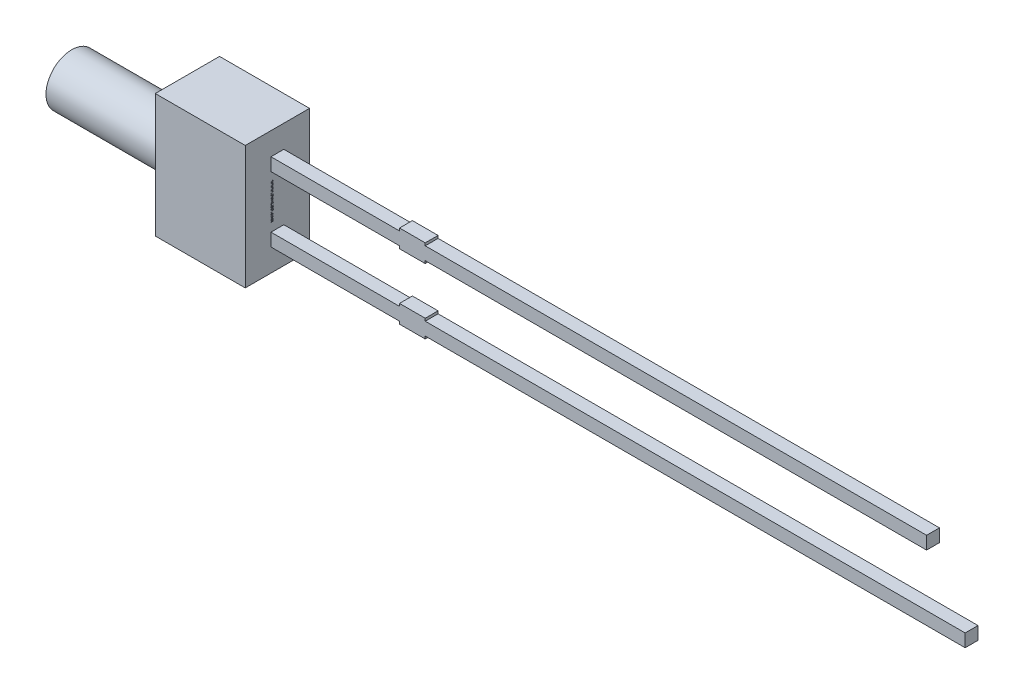
from build123d import *

# Parameters (mm, degrees)
SKETCH1_W          = 3.5
SKETCH1_H          = 4.8
EXTRUDE1_DEPTH     = 1.25
SKETCH1_4_W        = 5
SKETCH1_4_H        = 0.5
SKETCH1_4_W_2      = 1
SKETCH1_4_W_3      = 19.5
SKETCH1_4_H_2      = 0.1
SKETCH1_4_W_4      = 21
EXTRUDE2_DEPTH     = 0.25
SKETCH3_R          = 1
EXTRUDE3_DEPTH     = 4.5
SKETCH4_W          = 0.026582278
SKETCH4_H          = 0.025316456
CUT_EXTRUDE1_DEPTH = 0.01


with BuildPart() as part:
    # Sketch1 → Extrude1 (new body, symmetric)
    with BuildSketch(Plane.XY):
        Rectangle(SKETCH1_W, SKETCH1_H)
    extrude(amount=EXTRUDE1_DEPTH, both=True)

    # Sketch1_4 → Extrude2 (add, symmetric)
    with BuildSketch(Plane.XY):
        with Locations((4.25, 1.27)):
            Rectangle(SKETCH1_4_W, SKETCH1_4_H)
        with Locations((7.25, 1.27)):
            Rectangle(SKETCH1_4_W_2, SKETCH1_4_H)
        with Locations((17.5, 1.27)):
            Rectangle(SKETCH1_4_W_3, SKETCH1_4_H)
        with Locations((7.25, 1.57)):
            Rectangle(SKETCH1_4_W_2, SKETCH1_4_H_2)
        with Locations((7.25, 0.97)):
            Rectangle(SKETCH1_4_W_2, SKETCH1_4_H_2)
        with Locations((7.25, -1.27)):
            Rectangle(SKETCH1_4_W_2, SKETCH1_4_H)
        with Locations((7.25, -0.97)):
            Rectangle(SKETCH1_4_W_2, SKETCH1_4_H_2)
        with Locations((18.25, -1.27)):
            Rectangle(SKETCH1_4_W_4, SKETCH1_4_H)
        with Locations((4.25, -1.27)):
            Rectangle(SKETCH1_4_W, SKETCH1_4_H)
        with Locations((7.25, -1.57)):
            Rectangle(SKETCH1_4_W_2, SKETCH1_4_H_2)
    extrude(amount=EXTRUDE2_DEPTH, both=True)

    # Sketch3 → Extrude3 (add)
    with BuildSketch(Plane.ZY.offset(1.75)):
        with Locations(Location((0, 0, 0), (0, 0, 180))):  # turned: the seam where the file's is
            Circle(SKETCH3_R)
    extrude(amount=EXTRUDE3_DEPTH)

    # Sketch4 → Cut-Extrude1 (cut)
    with BuildSketch(Plane(origin=(1.75, 0, 0), x_dir=(0, 0, -1), z_dir=(1, 0, 0))):
        Polygon((-0.175316456, 0.572151899), (-0.25, 0.595609177), (-0.25, 0.620352057), (-0.199663766, 0.636768196), (-0.25, 0.652294304), (-0.25, 0.678026108), (-0.175316456, 0.701265823), (-0.175316456, 0.676087816), (-0.226799842, 0.663093354), (-0.175316456, 0.646677215), (-0.175316456, 0.625178006), (-0.226799842, 0.608860759), (-0.175316456, 0.596044304), align=None)
        Polygon((-0.175316456, 0.437974684), (-0.25, 0.461431962), (-0.25, 0.486174842), (-0.199663766, 0.502590981), (-0.25, 0.518117089), (-0.25, 0.543848892), (-0.175316456, 0.567088608), (-0.175316456, 0.541910601), (-0.226799842, 0.528916139), (-0.175316456, 0.5125), (-0.175316456, 0.491000791), (-0.226799842, 0.474683544), (-0.175316456, 0.461867089), align=None)
        Polygon((-0.175316456, 0.303797468), (-0.25, 0.327254747), (-0.25, 0.351997627), (-0.199663766, 0.368413766), (-0.25, 0.383939873), (-0.25, 0.409671677), (-0.175316456, 0.432911392), (-0.175316456, 0.407733386), (-0.226799842, 0.394738924), (-0.175316456, 0.378322785), (-0.175316456, 0.356823576), (-0.226799842, 0.340506329), (-0.175316456, 0.327689873), align=None)
        with Locations((-0.236708861, 0.275949367)):
            Rectangle(SKETCH4_W, SKETCH4_H)
        with BuildLine():
            add(Edge.make_bspline(
                [(-0.218829114, 0.159493671), (-0.220051248, 0.159530169), (-0.22245111, 0.15960184), (-0.225958798, 0.160211426), (-0.229283102, 0.161205393), (-0.232447248, 0.162577732), (-0.235416736, 0.164371189), (-0.238219628, 0.16655446), (-0.240824172, 0.169143343), (-0.243260547, 0.172090146), (-0.245442658, 0.175387089), (-0.247348691, 0.178984804), (-0.248943362, 0.18286483), (-0.250282428, 0.187013042), (-0.251270861, 0.191459588), (-0.251994849, 0.196177087), (-0.252468166, 0.201170514), (-0.252510134, 0.204594091), (-0.252531646, 0.206348892)],
                knots=[0, 0, 0, 0, 0.907312236, 1.78165839, 2.635367075, 3.479697475, 4.336364812, 5.205276731, 6.11257575, 7.058770404, 8.040786331, 9.044147278, 10.078219212, 11.153049307, 12.278104542, 13.457648573, 14.696882856, 16, 16, 16, 16], degree=3))
            add(Edge.make_bspline(
                [(-0.252531646, 0.206348892), (-0.252507574, 0.208367148), (-0.252460949, 0.21227633), (-0.25203235, 0.217939855), (-0.251386211, 0.223207892), (-0.250419669, 0.228103607), (-0.249218904, 0.232708206), (-0.247927612, 0.237141474), (-0.246463197, 0.241422786), (-0.245363039, 0.244195876), (-0.244818038, 0.24556962)],
                knots=[0, 0, 0, 0, 1.203215828, 2.33052265, 3.384689099, 4.366106119, 5.303329643, 6.221311756, 7.118865988, 8, 8, 8, 8], degree=3))
            Line((-0.244818038, 0.24556962), (-0.220886076, 0.24556962))
            Line((-0.220886076, 0.24556962), (-0.220886076, 0.242721519))
            add(Edge.make_bspline(
                [(-0.220886076, 0.242721519), (-0.221967531, 0.241356205), (-0.224124092, 0.238633592), (-0.226886697, 0.234200359), (-0.22928886, 0.229552713), (-0.231262862, 0.224707243), (-0.232849186, 0.219810398), (-0.233942713, 0.21493502), (-0.234690062, 0.210169433), (-0.234770569, 0.207010864), (-0.234810127, 0.205458861)],
                knots=[0, 0, 0, 0, 1.030622468, 2.055194264, 3.087043286, 4.125157485, 5.149848264, 6.130935704, 7.081611712, 8, 8, 8, 8], degree=3))
            add(Edge.make_bspline(
                [(-0.234810127, 0.205458861), (-0.234809232, 0.205030082), (-0.234807317, 0.2041121), (-0.234678474, 0.202644063), (-0.234585311, 0.200985464), (-0.234376093, 0.199206598), (-0.23415751, 0.197415781), (-0.23377719, 0.195761121), (-0.233415351, 0.194257482), (-0.233047173, 0.193351), (-0.232871835, 0.192919304)],
                knots=[0, 0, 0, 0, 0.806378557, 1.726393851, 2.771014456, 3.931269413, 5.096090628, 6.161710732, 7.124547685, 8, 8, 8, 8], degree=3))
            add(Edge.make_bspline(
                [(-0.232871835, 0.192919304), (-0.232644012, 0.192439517), (-0.23219629, 0.191496634), (-0.231378683, 0.190201714), (-0.230507381, 0.189019042), (-0.229541962, 0.187957582), (-0.228364053, 0.187107314), (-0.226963197, 0.186479113), (-0.225312897, 0.186136019), (-0.224137886, 0.186096725), (-0.223516614, 0.186075949)],
                knots=[0, 0, 0, 0, 1.024407818, 2.013179384, 2.949802342, 3.859052226, 4.77034807, 5.732977883, 6.801339628, 8, 8, 8, 8], degree=3))
            add(Edge.make_bspline(
                [(-0.223516614, 0.186075949), (-0.222970718, 0.186107391), (-0.221897325, 0.186169215), (-0.220369329, 0.186751006), (-0.218947452, 0.187633905), (-0.217686737, 0.188920927), (-0.216529299, 0.190515003), (-0.215559002, 0.19247074), (-0.214678928, 0.194723719), (-0.214261659, 0.196368178), (-0.214042722, 0.197231013)],
                knots=[0, 0, 0, 0, 0.825212765, 1.622611382, 2.449701629, 3.348069183, 4.336544339, 5.428209675, 6.6506027, 8, 8, 8, 8], degree=3))
            add(Edge.make_bspline(
                [(-0.214042722, 0.197231013), (-0.213594981, 0.19919974), (-0.212677791, 0.203232648), (-0.211530684, 0.209380757), (-0.210264611, 0.215510984), (-0.20905507, 0.219469696), (-0.20846519, 0.221400316)],
                knots=[0, 0, 0, 0, 0.976104583, 1.999535498, 3.024395274, 4, 4, 4, 4], degree=3))
            add(Edge.make_bspline(
                [(-0.20846519, 0.221400316), (-0.208112197, 0.222438832), (-0.207425064, 0.224460401), (-0.206263439, 0.227351945), (-0.204993487, 0.230013057), (-0.203638356, 0.232453168), (-0.202164358, 0.23465249), (-0.200630968, 0.236647679), (-0.198977131, 0.238391205), (-0.197245211, 0.239938889), (-0.195393209, 0.241262203), (-0.193449072, 0.242416954), (-0.191388607, 0.243392589), (-0.189227318, 0.244201473), (-0.18694845, 0.244818545), (-0.184571576, 0.245239801), (-0.182088216, 0.24553819), (-0.180393863, 0.245559001), (-0.179529272, 0.24556962)],
                knots=[0, 0, 0, 0, 1.287286806, 2.505824366, 3.654938963, 4.74627059, 5.778586806, 6.75996495, 7.696030012, 8.595059759, 9.482019644, 10.363222407, 11.245851011, 12.154256429, 13.068444161, 14.012503255, 14.985824751, 16, 16, 16, 16], degree=3))
            add(Edge.make_bspline(
                [(-0.179529272, 0.24556962), (-0.178373127, 0.245532318), (-0.176097855, 0.245458909), (-0.172768811, 0.24485748), (-0.169620074, 0.24383089), (-0.166616611, 0.242444827), (-0.163803525, 0.240616199), (-0.161124978, 0.238431404), (-0.158653386, 0.235807357), (-0.156353053, 0.232830235), (-0.154273654, 0.229542851), (-0.152443098, 0.226003867), (-0.150906446, 0.222234578), (-0.149632552, 0.218249032), (-0.148677881, 0.214030563), (-0.14795895, 0.20959333), (-0.147545768, 0.204919541), (-0.147494518, 0.20172812), (-0.147468354, 0.200098892)],
                knots=[0, 0, 0, 0, 0.894990994, 1.761326291, 2.609044902, 3.454222546, 4.315366365, 5.200560057, 6.125081389, 7.100429509, 8.110379559, 9.133447974, 10.182136699, 11.259192205, 12.370181258, 13.528580438, 14.738335141, 16, 16, 16, 16], degree=3))
            add(Edge.make_bspline(
                [(-0.147468354, 0.200098892), (-0.147490546, 0.198430205), (-0.147534891, 0.19509566), (-0.147912869, 0.190114218), (-0.148468097, 0.185153716), (-0.149309803, 0.180289886), (-0.15028622, 0.175599331), (-0.151382015, 0.171186095), (-0.15261998, 0.167106634), (-0.153574325, 0.16453297), (-0.15403481, 0.163291139)],
                knots=[0, 0, 0, 0, 1.065403572, 2.129000689, 3.188532477, 4.251604565, 5.279552602, 6.247508681, 7.154397237, 8, 8, 8, 8], degree=3))
            Line((-0.15403481, 0.163291139), (-0.176582278, 0.163291139))
            Line((-0.176582278, 0.163291139), (-0.176582278, 0.166119462))
            add(Edge.make_bspline(
                [(-0.176582278, 0.166119462), (-0.175781932, 0.167192367), (-0.174145202, 0.169386485), (-0.17206153, 0.173046122), (-0.170103664, 0.177004358), (-0.168419505, 0.181283188), (-0.166960024, 0.185742216), (-0.165940858, 0.190325174), (-0.165299048, 0.194951338), (-0.165226273, 0.198053049), (-0.165189873, 0.19960443)],
                knots=[0, 0, 0, 0, 0.892283326, 1.824742884, 2.804416662, 3.836872171, 4.8899239, 5.931447339, 6.965372909, 8, 8, 8, 8], degree=3))
            add(Edge.make_bspline(
                [(-0.165189873, 0.19960443), (-0.165211326, 0.200700098), (-0.165254228, 0.202891315), (-0.165644912, 0.206159523), (-0.166275806, 0.209401584), (-0.167095088, 0.211442107), (-0.167503956, 0.212460443)],
                knots=[0, 0, 0, 0, 0.999146175, 1.998183711, 3.000980573, 4, 4, 4, 4], degree=3))
            add(Edge.make_bspline(
                [(-0.167503956, 0.212460443), (-0.167705423, 0.212893946), (-0.168108222, 0.213760664), (-0.168880786, 0.214967308), (-0.169809597, 0.216071977), (-0.170861589, 0.217064055), (-0.172017962, 0.217932452), (-0.173292788, 0.218547803), (-0.174655703, 0.218923676), (-0.175590934, 0.218965835), (-0.176068038, 0.218987342)],
                knots=[0, 0, 0, 0, 1.00524851, 2.009826503, 3.004679593, 4.035271301, 5.048246368, 6.034938417, 6.997532266, 8, 8, 8, 8], degree=3))
            add(Edge.make_bspline(
                [(-0.176068038, 0.218987342), (-0.176706203, 0.218952904), (-0.177925679, 0.218887095), (-0.179641475, 0.218280511), (-0.181119909, 0.217295678), (-0.182114829, 0.216135073), (-0.182812267, 0.215017943), (-0.183322777, 0.213982284), (-0.183806136, 0.212773057), (-0.184303605, 0.211401809), (-0.184794792, 0.209865482), (-0.185270339, 0.208156925), (-0.185719635, 0.206274208), (-0.186005825, 0.204958333), (-0.186155063, 0.204272152)],
                knots=[0, 0, 0, 0, 1.173816843, 2.243057204, 3.312297565, 4.415174738, 5.03266065, 5.73970059, 6.541434878, 7.433956553, 8.430083051, 9.515931566, 10.70464786, 12, 12, 12, 12], degree=3))
            add(Edge.make_bspline(
                [(-0.186155063, 0.204272152), (-0.186531125, 0.202439363), (-0.187270003, 0.198838337), (-0.188373491, 0.193437153), (-0.18964846, 0.18793438), (-0.190797263, 0.184269053), (-0.191396361, 0.182357595)],
                knots=[0, 0, 0, 0, 0.995744513, 1.956417928, 2.934277412, 4, 4, 4, 4], degree=3))
            add(Edge.make_bspline(
                [(-0.191396361, 0.182357595), (-0.191715605, 0.181411041), (-0.192340097, 0.179559428), (-0.19342638, 0.176918797), (-0.194600363, 0.174471738), (-0.195841894, 0.172204706), (-0.19718586, 0.170130736), (-0.198608507, 0.168236053), (-0.200135416, 0.166552235), (-0.201748644, 0.16505467), (-0.203458744, 0.16373551), (-0.205297817, 0.162603212), (-0.207246619, 0.161630984), (-0.209332819, 0.160861379), (-0.211527406, 0.160243358), (-0.213858774, 0.159820261), (-0.21630315, 0.159526278), (-0.217977728, 0.159504661), (-0.218829114, 0.159493671)],
                knots=[0, 0, 0, 0, 1.237467875, 2.420686895, 3.535046182, 4.599015201, 5.620884487, 6.594603852, 7.531477383, 8.433220087, 9.318759595, 10.202828513, 11.105163009, 12.01247538, 12.953896178, 13.926381251, 14.945733412, 16, 16, 16, 16], degree=3))
        make_face()
        with BuildLine():
            Line((-0.25, 0.067088608), (-0.25, 0.091139241))
            Line((-0.25, 0.091139241), (-0.242167722, 0.091139241))
            add(Edge.make_bspline(
                [(-0.242167722, 0.091139241), (-0.24297628, 0.092232549), (-0.244535168, 0.094340433), (-0.246615386, 0.097513458), (-0.248390652, 0.100539548), (-0.249949873, 0.103453039), (-0.251125258, 0.106475242), (-0.251953324, 0.109706756), (-0.252453097, 0.113209581), (-0.252504881, 0.115636475), (-0.252531646, 0.116890823)],
                knots=[0, 0, 0, 0, 1.150872466, 2.218865267, 3.209461834, 4.120482262, 5.012764827, 5.946708227, 6.938749913, 8, 8, 8, 8], degree=3))
            add(Edge.make_bspline(
                [(-0.252531646, 0.116890823), (-0.252508927, 0.117907175), (-0.252464686, 0.119886305), (-0.252119808, 0.122763545), (-0.251582157, 0.125471173), (-0.250774566, 0.127986213), (-0.249808763, 0.130350202), (-0.248528805, 0.132487752), (-0.247098631, 0.134491354), (-0.245391585, 0.136273026), (-0.243493852, 0.137888648), (-0.241361392, 0.139271198), (-0.239028466, 0.140448909), (-0.236476612, 0.141390006), (-0.233718309, 0.142145096), (-0.230739061, 0.142669028), (-0.227551934, 0.142989621), (-0.225356803, 0.14302156), (-0.224228639, 0.143037975)],
                knots=[0, 0, 0, 0, 1.109008058, 2.159558935, 3.158726032, 4.116861086, 5.039058877, 5.938775559, 6.82970133, 7.720510853, 8.624361809, 9.544451588, 10.487360536, 11.471068125, 12.508000841, 13.604731202, 14.768976642, 16, 16, 16, 16], degree=3))
            Line((-0.224228639, 0.143037975), (-0.175316456, 0.143037975))
            Line((-0.175316456, 0.143037975), (-0.175316456, 0.118987342))
            Line((-0.175316456, 0.118987342), (-0.21289557, 0.118987342))
            add(Edge.make_bspline(
                [(-0.21289557, 0.118987342), (-0.213812041, 0.118985706), (-0.215566256, 0.118982576), (-0.218072063, 0.118900237), (-0.220340235, 0.118779336), (-0.222382264, 0.118640631), (-0.224229015, 0.118387615), (-0.225895176, 0.118009906), (-0.227414778, 0.11753908), (-0.228321479, 0.117074761), (-0.228757911, 0.116851266)],
                knots=[0, 0, 0, 0, 1.361401701, 2.605856924, 3.723918663, 4.735739235, 5.645738665, 6.489217889, 7.27279937, 8, 8, 8, 8], degree=3))
            add(Edge.make_bspline(
                [(-0.228757911, 0.116851266), (-0.229156626, 0.116621259), (-0.229940466, 0.116169086), (-0.230946644, 0.115248796), (-0.231790911, 0.114170053), (-0.23244694, 0.112892449), (-0.232945889, 0.111405901), (-0.233286125, 0.109677971), (-0.233501627, 0.107692609), (-0.233529535, 0.106283591), (-0.233544304, 0.105537975)],
                knots=[0, 0, 0, 0, 0.849138082, 1.669332372, 2.503455908, 3.370611167, 4.311442699, 5.394692208, 6.621337967, 8, 8, 8, 8], degree=3))
            add(Edge.make_bspline(
                [(-0.233544304, 0.105537975), (-0.233526947, 0.104996691), (-0.233491259, 0.103883773), (-0.233258814, 0.102172461), (-0.232902139, 0.100375884), (-0.232242283, 0.097861301), (-0.231056104, 0.094694674), (-0.229701697, 0.092335372), (-0.229015032, 0.091139241)],
                knots=[0, 0, 0, 0, 0.638127216, 1.312033637, 2.033062677, 2.79661882, 4.375931797, 6, 6, 6, 6], degree=3))
            Line((-0.229015032, 0.091139241), (-0.175316456, 0.091139241))
            Line((-0.175316456, 0.091139241), (-0.175316456, 0.067088608))
            Line((-0.175316456, 0.067088608), (-0.25, 0.067088608))
        make_face()
        with BuildLine():
            Line((-0.25, -0.030379747), (-0.25, -0.006329114))
            Line((-0.25, -0.006329114), (-0.212420886, -0.006329114))
            add(Edge.make_bspline(
                [(-0.212420886, -0.006329114), (-0.210890843, -0.0063046), (-0.207839818, -0.006255716), (-0.204077407, -0.005973592), (-0.201235083, -0.00559507), (-0.199397202, -0.005225415), (-0.197849063, -0.004793715), (-0.196963303, -0.004381435), (-0.196558544, -0.004193038)],
                knots=[0, 0, 0, 0, 1.709124929, 3.408128882, 4.211124727, 4.91016634, 5.501986363, 6, 6, 6, 6], degree=3))
            add(Edge.make_bspline(
                [(-0.196558544, -0.004193038), (-0.196160491, -0.003948575), (-0.195380051, -0.003469272), (-0.194367038, -0.002531948), (-0.193538197, -0.001438061), (-0.192856647, -0.000167292), (-0.192386066, 0.001323905), (-0.191992836, 0.003040645), (-0.191825927, 0.005027263), (-0.191790767, 0.006434533), (-0.191772152, 0.007179589)],
                knots=[0, 0, 0, 0, 0.86006424, 1.686277094, 2.52783008, 3.38194165, 4.331801563, 5.402842185, 6.624978739, 8, 8, 8, 8], degree=3))
            add(Edge.make_bspline(
                [(-0.191772152, 0.007179589), (-0.191828889, 0.00831141), (-0.191944743, 0.010622505), (-0.19265625, 0.013484698), (-0.193475209, 0.015815302), (-0.19423404, 0.017667827), (-0.195205482, 0.019576457), (-0.195927304, 0.020855869), (-0.196301424, 0.021518987)],
                knots=[0, 0, 0, 0, 1.338371478, 2.732853438, 3.468019217, 4.261884641, 5.099136535, 6, 6, 6, 6], degree=3))
            Line((-0.196301424, 0.021518987), (-0.25, 0.021518987))
            Line((-0.25, 0.021518987), (-0.25, 0.04556962))
            Line((-0.25, 0.04556962), (-0.175316456, 0.04556962))
            Line((-0.175316456, 0.04556962), (-0.175316456, 0.021518987))
            Line((-0.175316456, 0.021518987), (-0.183148734, 0.021518987))
            add(Edge.make_bspline(
                [(-0.183148734, 0.021518987), (-0.182342583, 0.020461581), (-0.18077336, 0.018403276), (-0.17873294, 0.015224038), (-0.176934171, 0.01214014), (-0.175421354, 0.009087131), (-0.174214579, 0.005972176), (-0.17340359, 0.002709417), (-0.172859787, -0.000706989), (-0.172810094, -0.003043704), (-0.17278481, -0.004232595)],
                knots=[0, 0, 0, 0, 1.126119141, 2.192057864, 3.198061997, 4.149848529, 5.076251285, 6.021887753, 6.99356175, 8, 8, 8, 8], degree=3))
            add(Edge.make_bspline(
                [(-0.17278481, -0.004232595), (-0.172810199, -0.005228866), (-0.172859763, -0.007173765), (-0.173169473, -0.010008526), (-0.173720137, -0.012679947), (-0.174517966, -0.015172221), (-0.175503578, -0.017514841), (-0.176735093, -0.019676785), (-0.178193516, -0.021668856), (-0.179854519, -0.023497257), (-0.181744245, -0.025128075), (-0.18386151, -0.026545111), (-0.186204606, -0.027725092), (-0.188764915, -0.028695805), (-0.191530024, -0.029470228), (-0.19452599, -0.029985359), (-0.197730169, -0.030339143), (-0.199946212, -0.030365941), (-0.201087816, -0.030379747)],
                knots=[0, 0, 0, 0, 1.08848837, 2.124922927, 3.110950502, 4.063144162, 4.979605775, 5.882838355, 6.774625441, 7.671951181, 8.57587277, 9.494821853, 10.448322275, 11.435533005, 12.482327682, 13.580118324, 14.753386918, 16, 16, 16, 16], degree=3))
            Line((-0.201087816, -0.030379747), (-0.25, -0.030379747))
        make_face()
        Polygon((-0.25, -0.125316456), (-0.25, -0.053164557), (-0.15, -0.053164557), (-0.15, -0.078481013), (-0.231012658, -0.078481013), (-0.231012658, -0.125316456), align=None)
        Polygon((-0.25, -0.212658228), (-0.25, -0.140506329), (-0.15, -0.140506329), (-0.15, -0.212658228), (-0.168987342, -0.212658228), (-0.168987342, -0.165822785), (-0.186708861, -0.165822785), (-0.186708861, -0.208860759), (-0.205696203, -0.208860759), (-0.205696203, -0.165822785), (-0.231012658, -0.165822785), (-0.231012658, -0.212658228), align=None)
        with BuildLine():
            add(Edge.make_bspline(
                [(-0.200098892, -0.329113924), (-0.201246581, -0.329094609), (-0.203519467, -0.329056357), (-0.206884274, -0.328761165), (-0.210149949, -0.32823514), (-0.213334198, -0.327555959), (-0.216413126, -0.326633453), (-0.219420703, -0.325551739), (-0.222326196, -0.324242093), (-0.225127631, -0.322737241), (-0.227799734, -0.321087768), (-0.230319942, -0.319313019), (-0.23270316, -0.31746724), (-0.234898054, -0.315477927), (-0.236940074, -0.313398746), (-0.238830888, -0.311223217), (-0.240534319, -0.308918153), (-0.241557203, -0.30731099), (-0.242068829, -0.30650712)],
                knots=[0, 0, 0, 0, 1.105570398, 2.18947457, 3.250358341, 4.290584537, 5.323553275, 6.344225964, 7.367641686, 8.3905646, 9.405808457, 10.390761353, 11.358902336, 12.307789878, 13.241960776, 14.165076779, 15.082208636, 16, 16, 16, 16], degree=3))
            add(Edge.make_bspline(
                [(-0.242068829, -0.30650712), (-0.242780968, -0.305267892), (-0.244208881, -0.302783112), (-0.245877472, -0.298799278), (-0.247281588, -0.294673795), (-0.248336012, -0.290323409), (-0.249063056, -0.285676399), (-0.249623862, -0.28067499), (-0.249925622, -0.275267401), (-0.249974642, -0.271532506), (-0.25, -0.269600475)],
                knots=[0, 0, 0, 0, 0.896288622, 1.797150563, 2.705281913, 3.629615989, 4.602417572, 5.655716007, 6.787320449, 8, 8, 8, 8], degree=3))
            Line((-0.25, -0.269600475), (-0.25, -0.234177215))
            Line((-0.25, -0.234177215), (-0.15, -0.234177215))
            Line((-0.15, -0.234177215), (-0.15, -0.270609177))
            add(Edge.make_bspline(
                [(-0.15, -0.270609177), (-0.150016611, -0.272587909), (-0.150048652, -0.276404637), (-0.150466242, -0.281921476), (-0.151063066, -0.287026684), (-0.151987937, -0.291712032), (-0.153103282, -0.296012037), (-0.154462411, -0.299937513), (-0.155961118, -0.303549287), (-0.157234811, -0.305728129), (-0.157852057, -0.306784019)],
                knots=[0, 0, 0, 0, 1.267175336, 2.444223962, 3.542125549, 4.557526608, 5.500936977, 6.385043188, 7.217374394, 8, 8, 8, 8], degree=3))
            add(Edge.make_bspline(
                [(-0.157852057, -0.306784019), (-0.158388598, -0.307634972), (-0.159455511, -0.309327097), (-0.161237363, -0.311728312), (-0.16319344, -0.313957739), (-0.165245259, -0.316086242), (-0.167448146, -0.318066059), (-0.169786853, -0.319909259), (-0.172264947, -0.321613076), (-0.174874416, -0.323171039), (-0.177604468, -0.324591854), (-0.180477527, -0.32578116), (-0.183456057, -0.326830509), (-0.186565019, -0.327636046), (-0.189772856, -0.32833396), (-0.1931142, -0.328768694), (-0.196566688, -0.329055305), (-0.198911578, -0.32909422), (-0.200098892, -0.329113924)],
                knots=[0, 0, 0, 0, 0.964065863, 1.917049184, 2.86229036, 3.805247319, 4.749389377, 5.698846072, 6.657678277, 7.629829384, 8.610569287, 9.604676042, 10.607940105, 11.6349849, 12.681042988, 13.752616828, 14.862056989, 16, 16, 16, 16], degree=3))
        make_face()
        with BuildLine():
            add(Edge.make_bspline(
                [(-0.199940665, -0.302531646), (-0.199135905, -0.302521405), (-0.197557321, -0.302501317), (-0.195241806, -0.30230975), (-0.193012156, -0.302050694), (-0.190877464, -0.30161964), (-0.188817893, -0.301119993), (-0.186860399, -0.300477843), (-0.184980826, -0.299753447), (-0.183203337, -0.298871809), (-0.181494955, -0.297898172), (-0.17990944, -0.296750679), (-0.178396553, -0.295502341), (-0.176968569, -0.294124054), (-0.175662673, -0.292581114), (-0.174432597, -0.290921012), (-0.173304271, -0.289120654), (-0.172644221, -0.287847665), (-0.172310127, -0.287203323)],
                knots=[0, 0, 0, 0, 1.152093354, 2.259898929, 3.325467225, 4.364140538, 5.376172865, 6.358396836, 7.312077728, 8.257828931, 9.196960457, 10.124297759, 11.056236784, 12.004246951, 12.961658638, 13.947279359, 14.960983522, 16, 16, 16, 16], degree=3))
            add(Edge.make_bspline(
                [(-0.172310127, -0.287203323), (-0.172003415, -0.286528425), (-0.17139549, -0.285190731), (-0.170664298, -0.283119908), (-0.170091462, -0.281030524), (-0.169660604, -0.278828925), (-0.169338673, -0.276359165), (-0.169141415, -0.273433583), (-0.168999245, -0.269977674), (-0.168991494, -0.267490959), (-0.168987342, -0.266159019)],
                knots=[0, 0, 0, 0, 0.826967603, 1.639107464, 2.447640171, 3.242670507, 4.14065217, 5.225198036, 6.513753944, 8, 8, 8, 8], degree=3))
            Line((-0.168987342, -0.266159019), (-0.168987342, -0.259493671))
            Line((-0.168987342, -0.259493671), (-0.231012658, -0.259493671))
            Line((-0.231012658, -0.259493671), (-0.231012658, -0.266159019))
            add(Edge.make_bspline(
                [(-0.231012658, -0.266159019), (-0.231007909, -0.266917226), (-0.230998739, -0.268380991), (-0.230955677, -0.270497235), (-0.230908789, -0.272463031), (-0.230792327, -0.274267902), (-0.230719681, -0.275926587), (-0.230541302, -0.277413368), (-0.230399122, -0.278755857), (-0.230131399, -0.280323454), (-0.229715216, -0.28217662), (-0.229037037, -0.28433788), (-0.228186642, -0.286478414), (-0.227501675, -0.287866987), (-0.227155854, -0.288568038)],
                knots=[0, 0, 0, 0, 1.186793418, 2.291178421, 3.313283093, 4.264083014, 5.122158624, 5.910777728, 6.607099052, 7.234812932, 8.398911528, 9.577194775, 10.776795607, 12, 12, 12, 12], degree=3))
            add(Edge.make_bspline(
                [(-0.227155854, -0.288568038), (-0.226814338, -0.289153154), (-0.226140824, -0.29030708), (-0.22500675, -0.291930584), (-0.223799025, -0.293438302), (-0.222510574, -0.294834314), (-0.221122333, -0.296097614), (-0.219655791, -0.297249633), (-0.218107813, -0.298280082), (-0.215914295, -0.299515471), (-0.212883358, -0.300738716), (-0.208915972, -0.301778259), (-0.204556209, -0.30241513), (-0.201518591, -0.302491812), (-0.199940665, -0.302531646)],
                knots=[0, 0, 0, 0, 0.755160452, 1.489275589, 2.205657296, 2.907868421, 3.605098304, 4.296256403, 4.985378686, 5.676536785, 7.100390329, 8.614249252, 10.241231541, 12, 12, 12, 12], degree=3))
        make_face(mode=Mode.SUBTRACT)
        with Locations((-0.236708861, -0.360759494)):
            Rectangle(SKETCH4_W, SKETCH4_H)
        with BuildLine():
            add(Edge.make_bspline(
                [(-0.252531646, -0.435403481), (-0.252509834, -0.433813368), (-0.252467023, -0.430692232), (-0.251990106, -0.42612089), (-0.25127241, -0.421755717), (-0.250251504, -0.417609409), (-0.248904008, -0.413695618), (-0.247251072, -0.41003198), (-0.245265888, -0.406625123), (-0.243686679, -0.404566476), (-0.242899525, -0.403540348)],
                knots=[0, 0, 0, 0, 1.123670284, 2.205584497, 3.245308791, 4.249063313, 5.220352711, 6.167273909, 7.086481357, 8, 8, 8, 8], degree=3))
            add(Edge.make_bspline(
                [(-0.242899525, -0.403540348), (-0.242044751, -0.402588601), (-0.240338508, -0.400688786), (-0.237367081, -0.398222853), (-0.234084037, -0.396099767), (-0.230481815, -0.394314215), (-0.226565086, -0.392883291), (-0.222320424, -0.391860157), (-0.217759643, -0.391240912), (-0.21461171, -0.391173746), (-0.212994462, -0.391139241)],
                knots=[0, 0, 0, 0, 0.916457077, 1.82937027, 2.759194969, 3.714948755, 4.706655623, 5.743329475, 6.840637961, 8, 8, 8, 8], degree=3))
            add(Edge.make_bspline(
                [(-0.212994462, -0.391139241), (-0.211291235, -0.391178001), (-0.207990155, -0.391253124), (-0.203217967, -0.391916883), (-0.198800287, -0.392986496), (-0.194748378, -0.394524054), (-0.191055187, -0.396454496), (-0.187683352, -0.398718989), (-0.184640428, -0.401339514), (-0.182894988, -0.403346653), (-0.182021361, -0.404351266)],
                knots=[0, 0, 0, 0, 1.171797512, 2.271099083, 3.308930235, 4.294129479, 5.24602549, 6.17106565, 7.084581485, 8, 8, 8, 8], degree=3))
            add(Edge.make_bspline(
                [(-0.182021361, -0.404351266), (-0.181252774, -0.405377136), (-0.179706318, -0.407441268), (-0.177805619, -0.410844773), (-0.176210833, -0.414467988), (-0.174963188, -0.418297559), (-0.174009283, -0.422270367), (-0.173285439, -0.426330027), (-0.172864881, -0.43047628), (-0.172811629, -0.43326648), (-0.17278481, -0.434671677)],
                knots=[0, 0, 0, 0, 0.952130878, 1.915761808, 2.890227217, 3.891541892, 4.905612075, 5.925811839, 6.955400088, 8, 8, 8, 8], degree=3))
            add(Edge.make_bspline(
                [(-0.17278481, -0.434671677), (-0.172801812, -0.435918396), (-0.172835245, -0.438369867), (-0.173157354, -0.441970914), (-0.173690473, -0.445425455), (-0.174429076, -0.448730387), (-0.175320679, -0.451904334), (-0.17635982, -0.454954511), (-0.177493088, -0.457914321), (-0.178377623, -0.45981489), (-0.178817247, -0.460759494)],
                knots=[0, 0, 0, 0, 1.107648782, 2.178012834, 3.209595929, 4.211695017, 5.185427128, 6.137685403, 7.07440854, 8, 8, 8, 8], degree=3))
            Line((-0.178817247, -0.460759494), (-0.199367089, -0.460759494))
            Line((-0.199367089, -0.460759494), (-0.199367089, -0.45741693))
            add(Edge.make_bspline(
                [(-0.199367089, -0.45741693), (-0.198949869, -0.456917386), (-0.198048154, -0.45583775), (-0.196627402, -0.454051335), (-0.195097809, -0.451902393), (-0.194205863, -0.450248857), (-0.193730222, -0.449367089)],
                knots=[0, 0, 0, 0, 0.792826818, 1.713491785, 2.780691913, 4, 4, 4, 4], degree=3))
            add(Edge.make_bspline(
                [(-0.193730222, -0.449367089), (-0.193288264, -0.448439154), (-0.192382404, -0.446537209), (-0.19154957, -0.443981204), (-0.190981844, -0.441789202), (-0.190725422, -0.439971666), (-0.190535861, -0.438038046), (-0.190516354, -0.436702803), (-0.190506329, -0.436016614)],
                knots=[0, 0, 0, 0, 1.332524827, 2.731214173, 3.480270227, 4.267952375, 5.109889624, 6, 6, 6, 6], degree=3))
            add(Edge.make_bspline(
                [(-0.190506329, -0.436016614), (-0.190525879, -0.435251058), (-0.190563765, -0.433767448), (-0.190840821, -0.431605939), (-0.191319079, -0.429587528), (-0.191959179, -0.427684306), (-0.192846792, -0.425946243), (-0.193880429, -0.424319403), (-0.195106231, -0.422827143), (-0.196547173, -0.421507882), (-0.198127102, -0.420315156), (-0.199861217, -0.419295954), (-0.201707816, -0.418383498), (-0.203712265, -0.41768856), (-0.205841041, -0.417128822), (-0.208104161, -0.416739892), (-0.210503671, -0.416497934), (-0.212149979, -0.416470016), (-0.212994462, -0.416455696)],
                knots=[0, 0, 0, 0, 1.087302107, 2.107140881, 3.088415001, 4.030197574, 4.951552271, 5.852940509, 6.764198256, 7.685219758, 8.621679636, 9.570836121, 10.538340132, 11.542450476, 12.578202196, 13.66207107, 14.800746211, 16, 16, 16, 16], degree=3))
            add(Edge.make_bspline(
                [(-0.212994462, -0.416455696), (-0.213858618, -0.416470471), (-0.215537631, -0.416499177), (-0.217979242, -0.416732691), (-0.220260673, -0.417148582), (-0.222385993, -0.41771983), (-0.224352011, -0.418444178), (-0.226149408, -0.419349295), (-0.227806215, -0.420385652), (-0.229268827, -0.42163021), (-0.230585149, -0.422994093), (-0.231721283, -0.424508985), (-0.232669428, -0.426168224), (-0.233473891, -0.427950405), (-0.234052289, -0.429883445), (-0.234488981, -0.431939982), (-0.234777538, -0.434129537), (-0.234799101, -0.435639891), (-0.234810127, -0.436412184)],
                knots=[0, 0, 0, 0, 1.230336593, 2.390482092, 3.487897344, 4.52859895, 5.520747884, 6.465347575, 7.38981449, 8.296085817, 9.192433006, 10.084246191, 10.984321635, 11.908883871, 12.862027947, 13.850751296, 14.901019963, 16, 16, 16, 16], degree=3))
            add(Edge.make_bspline(
                [(-0.234810127, -0.436412184), (-0.234801999, -0.437138038), (-0.234786155, -0.438553063), (-0.234568078, -0.44061781), (-0.234292195, -0.442578718), (-0.233852787, -0.444414258), (-0.233310412, -0.446109524), (-0.232743906, -0.447669947), (-0.232139122, -0.449082395), (-0.231671567, -0.449943749), (-0.231447785, -0.450356013)],
                knots=[0, 0, 0, 0, 1.200823684, 2.340960236, 3.433630075, 4.476504061, 5.46014544, 6.378484521, 7.223905657, 8, 8, 8, 8], degree=3))
            add(Edge.make_bspline(
                [(-0.231447785, -0.450356013), (-0.23101789, -0.451056218), (-0.230186248, -0.452410785), (-0.228784682, -0.454249513), (-0.227370422, -0.455894382), (-0.226414205, -0.456918894), (-0.225949367, -0.45741693)],
                knots=[0, 0, 0, 0, 1.098601379, 2.125273733, 3.088655601, 4, 4, 4, 4], degree=3))
            Line((-0.225949367, -0.45741693), (-0.225949367, -0.460759494))
            Line((-0.225949367, -0.460759494), (-0.246657437, -0.460759494))
            add(Edge.make_bspline(
                [(-0.246657437, -0.460759494), (-0.247094931, -0.459814104), (-0.247970024, -0.457923097), (-0.249123896, -0.455008518), (-0.250092057, -0.452020545), (-0.250995137, -0.448972172), (-0.251683499, -0.445800089), (-0.252176622, -0.442477058), (-0.252477534, -0.43899556), (-0.252513362, -0.436617171), (-0.252531646, -0.435403481)],
                knots=[0, 0, 0, 0, 0.952012952, 1.904254716, 2.862729541, 3.822037426, 4.808956931, 5.82647221, 6.890850784, 8, 8, 8, 8], degree=3))
        make_face()
        with BuildLine():
            add(Edge.make_bspline(
                [(-0.212697785, -0.553164557), (-0.214202691, -0.553139862), (-0.217136157, -0.553091723), (-0.221407948, -0.552552407), (-0.225443946, -0.551739627), (-0.229231154, -0.550567096), (-0.232788429, -0.549086703), (-0.236078221, -0.547235764), (-0.239131451, -0.545064759), (-0.241921336, -0.542573722), (-0.244419846, -0.53977252), (-0.246615099, -0.536698338), (-0.248428541, -0.533324511), (-0.249940631, -0.5297102), (-0.251109866, -0.525825548), (-0.251922584, -0.521671329), (-0.252458054, -0.517254195), (-0.252506706, -0.514215776), (-0.252531646, -0.512658228)],
                knots=[0, 0, 0, 0, 1.120167703, 2.183507516, 3.201345984, 4.182878364, 5.131270247, 6.065524964, 6.98789854, 7.91635504, 8.84481154, 9.778033504, 10.722808862, 11.691211189, 12.691525459, 13.738229926, 14.840575679, 16, 16, 16, 16], degree=3))
            add(Edge.make_bspline(
                [(-0.252531646, -0.512658228), (-0.252506624, -0.511100707), (-0.252457811, -0.508062341), (-0.25192348, -0.503644832), (-0.251105529, -0.499485737), (-0.249949428, -0.49559643), (-0.248422879, -0.491987684), (-0.246615831, -0.488617817), (-0.244419638, -0.485544052), (-0.241921446, -0.482742566), (-0.239131219, -0.480252248), (-0.236079037, -0.478078657), (-0.232783083, -0.476236243), (-0.229240037, -0.474718389), (-0.225439199, -0.473585065), (-0.221408758, -0.472761602), (-0.217135938, -0.472225394), (-0.214202617, -0.472176819), (-0.212697785, -0.472151899)],
                knots=[0, 0, 0, 0, 1.15937715, 2.261678054, 3.308339936, 4.313313916, 5.277148057, 6.221884977, 7.155068972, 8.083487698, 9.011906424, 9.934242473, 10.868459181, 11.818729666, 12.798784262, 13.81658132, 14.879877871, 16, 16, 16, 16], degree=3))
            add(Edge.make_bspline(
                [(-0.212697785, -0.472151899), (-0.211186361, -0.472177022), (-0.208233351, -0.472226107), (-0.203934478, -0.472761477), (-0.199873828, -0.473579494), (-0.196065514, -0.474739526), (-0.192513914, -0.476255799), (-0.18921181, -0.478096824), (-0.186165235, -0.480293292), (-0.183375483, -0.48280279), (-0.180879102, -0.485614584), (-0.178706197, -0.488708516), (-0.176869539, -0.492060435), (-0.175347706, -0.495667634), (-0.174213141, -0.49955419), (-0.173395562, -0.503691132), (-0.17285749, -0.508088526), (-0.172809478, -0.511107264), (-0.17278481, -0.512658228)],
                knots=[0, 0, 0, 0, 1.124034801, 2.196132384, 3.217834281, 4.203147447, 5.152578239, 6.085969439, 7.010345409, 7.941219594, 8.872481455, 9.802010446, 10.748267785, 11.711250247, 12.709230373, 13.754967386, 14.846549946, 16, 16, 16, 16], degree=3))
            add(Edge.make_bspline(
                [(-0.17278481, -0.512658228), (-0.172809532, -0.514228966), (-0.172857665, -0.51728713), (-0.173393868, -0.521730542), (-0.174206873, -0.525904381), (-0.175373269, -0.529803006), (-0.176884682, -0.533428756), (-0.17871934, -0.536788831), (-0.180921398, -0.539860139), (-0.183428554, -0.542647393), (-0.186233956, -0.545127634), (-0.189283579, -0.54729655), (-0.192603295, -0.549103768), (-0.196158163, -0.550585538), (-0.199951933, -0.551757711), (-0.203986038, -0.552578696), (-0.208261035, -0.553084687), (-0.211193165, -0.553137471), (-0.212697785, -0.553164557)],
                knots=[0, 0, 0, 0, 1.167358552, 2.272800965, 3.322628764, 4.326027541, 5.29287265, 6.238482395, 7.166210353, 8.096447471, 9.020151799, 9.945039072, 10.873038967, 11.824425184, 12.804379233, 13.820580988, 14.881633558, 16, 16, 16, 16], degree=3))
        make_face()
        with BuildLine():
            add(Edge.make_bspline(
                [(-0.231190665, -0.523457278), (-0.230690658, -0.523812456), (-0.229673086, -0.524535285), (-0.227972663, -0.525405537), (-0.226150868, -0.526193542), (-0.224121587, -0.526811737), (-0.221819141, -0.527291059), (-0.219165549, -0.52760245), (-0.216130036, -0.527832094), (-0.213977323, -0.527842556), (-0.212836234, -0.527848101)],
                knots=[0, 0, 0, 0, 0.764956307, 1.556776596, 2.379454426, 3.241401993, 4.200532455, 5.312591107, 6.575484591, 8, 8, 8, 8], degree=3))
            add(Edge.make_bspline(
                [(-0.212836234, -0.527848101), (-0.211761353, -0.527830412), (-0.209701996, -0.527796522), (-0.206742233, -0.527610152), (-0.204058807, -0.527261478), (-0.201641411, -0.5267636), (-0.199470723, -0.526153829), (-0.19752836, -0.525427894), (-0.195809758, -0.524589376), (-0.194804527, -0.523903909), (-0.194323576, -0.523575949)],
                knots=[0, 0, 0, 0, 1.337076348, 2.561692668, 3.686680134, 4.69989255, 5.629188848, 6.488203485, 7.276684665, 8, 8, 8, 8], degree=3))
            add(Edge.make_bspline(
                [(-0.194323576, -0.523575949), (-0.193884293, -0.523238652), (-0.193022537, -0.522576962), (-0.191940352, -0.521400911), (-0.191042058, -0.520136352), (-0.190382017, -0.51875605), (-0.189862759, -0.517310883), (-0.189515923, -0.515802557), (-0.189287802, -0.514247405), (-0.189256424, -0.513193069), (-0.189240506, -0.512658228)],
                knots=[0, 0, 0, 0, 1.058684453, 2.076859345, 3.046867319, 4.017860406, 4.996047344, 5.981941452, 6.976284511, 8, 8, 8, 8], degree=3))
            add(Edge.make_bspline(
                [(-0.189240506, -0.512658228), (-0.189251453, -0.512130296), (-0.189272863, -0.511097679), (-0.189452545, -0.509595013), (-0.189747135, -0.508184065), (-0.190165068, -0.506844191), (-0.190760551, -0.505552217), (-0.191616975, -0.504317872), (-0.192692306, -0.503101936), (-0.193542825, -0.502363688), (-0.193987342, -0.501977848)],
                knots=[0, 0, 0, 0, 1.041978199, 2.038073998, 2.982578265, 3.884042198, 4.804014415, 5.778706634, 6.839057036, 8, 8, 8, 8], degree=3))
            add(Edge.make_bspline(
                [(-0.193987342, -0.501977848), (-0.194461968, -0.501644363), (-0.195460568, -0.500942719), (-0.197165089, -0.500059744), (-0.199127009, -0.49932839), (-0.20131075, -0.49863615), (-0.203781898, -0.498117886), (-0.206535176, -0.497717147), (-0.209589603, -0.497516433), (-0.21172182, -0.497484858), (-0.212836234, -0.497468354)],
                knots=[0, 0, 0, 0, 0.706185926, 1.485796665, 2.33004681, 3.254820698, 4.274138656, 5.402098861, 6.642194297, 8, 8, 8, 8], degree=3))
            add(Edge.make_bspline(
                [(-0.212836234, -0.497468354), (-0.213838698, -0.497477501), (-0.21577981, -0.497495212), (-0.218586195, -0.497694126), (-0.221190128, -0.498022802), (-0.22358016, -0.498499446), (-0.225765057, -0.49907369), (-0.227716716, -0.499821164), (-0.229471774, -0.500644638), (-0.230499515, -0.501344976), (-0.23099288, -0.501681171)],
                knots=[0, 0, 0, 0, 1.270915159, 2.460926195, 3.565223763, 4.596447547, 5.549594966, 6.425286377, 7.244063354, 8, 8, 8, 8], degree=3))
            add(Edge.make_bspline(
                [(-0.23099288, -0.501681171), (-0.231409366, -0.502021731), (-0.232230494, -0.502693168), (-0.233314509, -0.503842086), (-0.23417586, -0.505125798), (-0.234906348, -0.506477001), (-0.235435594, -0.507938804), (-0.235812201, -0.509490696), (-0.236027955, -0.511142431), (-0.236059682, -0.512275225), (-0.236075949, -0.512856013)],
                knots=[0, 0, 0, 0, 1.011121112, 1.993489184, 2.956264801, 3.910060304, 4.874908638, 5.87009835, 6.907993364, 8, 8, 8, 8], degree=3))
            add(Edge.make_bspline(
                [(-0.236075949, -0.512856013), (-0.236022367, -0.513856962), (-0.235915445, -0.515854325), (-0.235203793, -0.518269474), (-0.234354513, -0.520076797), (-0.233475258, -0.521316068), (-0.232435719, -0.522472259), (-0.231609742, -0.523125727), (-0.231190665, -0.523457278)],
                knots=[0, 0, 0, 0, 1.48399549, 2.96126462, 3.700919455, 4.439278468, 5.208134679, 6, 6, 6, 6], degree=3))
        make_face(mode=Mode.SUBTRACT)
        with BuildLine():
            Line((-0.196301424, -0.644303797), (-0.25, -0.644303797))
            Line((-0.25, -0.644303797), (-0.25, -0.620253165))
            Line((-0.25, -0.620253165), (-0.212143987, -0.620253165))
            add(Edge.make_bspline(
                [(-0.212143987, -0.620253165), (-0.211253953, -0.620247698), (-0.209546322, -0.62023721), (-0.207086708, -0.620204186), (-0.204838103, -0.620123915), (-0.202791904, -0.620016376), (-0.200932439, -0.619829431), (-0.199257604, -0.619518092), (-0.197752078, -0.619096595), (-0.19685113, -0.618688245), (-0.196420095, -0.61849288)],
                knots=[0, 0, 0, 0, 1.339742217, 2.570446543, 3.702449567, 4.726327994, 5.654556215, 6.512888379, 7.288529137, 8, 8, 8, 8], degree=3))
            add(Edge.make_bspline(
                [(-0.196420095, -0.61849288), (-0.196034728, -0.618282954), (-0.195270835, -0.61786683), (-0.194302974, -0.616998785), (-0.193492329, -0.615990476), (-0.192850874, -0.614810314), (-0.192352712, -0.613431631), (-0.192003366, -0.611816509), (-0.191822964, -0.609952652), (-0.191789727, -0.608630364), (-0.191772152, -0.607931171)],
                knots=[0, 0, 0, 0, 0.859345536, 1.703436662, 2.532498256, 3.390183975, 4.328249457, 5.402602062, 6.626559876, 8, 8, 8, 8], degree=3))
            add(Edge.make_bspline(
                [(-0.191772152, -0.607931171), (-0.191795714, -0.607343877), (-0.191843051, -0.60616399), (-0.19208459, -0.604405516), (-0.192586536, -0.602686303), (-0.193423174, -0.600467627), (-0.194639641, -0.597858323), (-0.19576153, -0.595885907), (-0.196301424, -0.594936709)],
                knots=[0, 0, 0, 0, 0.759443456, 1.525737455, 2.286422378, 3.068189154, 4.58910569, 6, 6, 6, 6], degree=3))
            Line((-0.196301424, -0.594936709), (-0.25, -0.594936709))
            Line((-0.25, -0.594936709), (-0.25, -0.570886076))
            Line((-0.25, -0.570886076), (-0.175316456, -0.570886076))
            Line((-0.175316456, -0.570886076), (-0.175316456, -0.594936709))
            Line((-0.175316456, -0.594936709), (-0.183148734, -0.594936709))
            add(Edge.make_bspline(
                [(-0.183148734, -0.594936709), (-0.182367252, -0.595957746), (-0.180849932, -0.597940187), (-0.178803995, -0.60095416), (-0.17704056, -0.603909643), (-0.175510003, -0.606810759), (-0.174254621, -0.609757207), (-0.173417856, -0.612851706), (-0.172885536, -0.616094453), (-0.172818794, -0.618312736), (-0.17278481, -0.619442247)],
                knots=[0, 0, 0, 0, 1.136140478, 2.205924536, 3.217129804, 4.176128364, 5.103417168, 6.04061054, 7.002313223, 8, 8, 8, 8], degree=3))
            add(Edge.make_bspline(
                [(-0.17278481, -0.619442247), (-0.172816556, -0.62064549), (-0.1728786, -0.622997145), (-0.173547861, -0.626409066), (-0.174552486, -0.629624954), (-0.176042919, -0.632580961), (-0.17787572, -0.635303105), (-0.180153427, -0.637694085), (-0.182799233, -0.639808625), (-0.184810869, -0.640898753), (-0.185838608, -0.641455696)],
                knots=[0, 0, 0, 0, 1.06605855, 2.083537511, 3.073064962, 4.046068917, 5.009676085, 5.97370914, 6.964773701, 8, 8, 8, 8], degree=3))
            add(Edge.make_bspline(
                [(-0.185838608, -0.641455696), (-0.184861648, -0.642637783), (-0.182957743, -0.644941441), (-0.180415047, -0.648495035), (-0.178160747, -0.651974192), (-0.176251034, -0.655414444), (-0.174706146, -0.658810095), (-0.173600545, -0.662189222), (-0.172917099, -0.665538003), (-0.172828397, -0.667771262), (-0.17278481, -0.668868671)],
                knots=[0, 0, 0, 0, 1.188124574, 2.315425566, 3.384037189, 4.39937427, 5.362203716, 6.270239573, 7.150007311, 8, 8, 8, 8], degree=3))
            add(Edge.make_bspline(
                [(-0.17278481, -0.668868671), (-0.172808185, -0.66985193), (-0.172853665, -0.671765088), (-0.173188962, -0.67454753), (-0.1737597, -0.677144118), (-0.174553952, -0.679566684), (-0.175577368, -0.681809925), (-0.176851198, -0.68386078), (-0.178357379, -0.685715362), (-0.180057184, -0.687408252), (-0.181991531, -0.688889581), (-0.184119192, -0.690193193), (-0.186470211, -0.69124157), (-0.188998325, -0.692146787), (-0.191735603, -0.692828576), (-0.194678201, -0.693319319), (-0.197818223, -0.693617336), (-0.199979558, -0.693652735), (-0.201087816, -0.693670886)],
                knots=[0, 0, 0, 0, 1.099321551, 2.138985818, 3.128101353, 4.067593225, 4.984602876, 5.878565082, 6.75932895, 7.650734189, 8.554641537, 9.477588118, 10.434248276, 11.427530835, 12.477080043, 13.583595796, 14.760951851, 16, 16, 16, 16], degree=3))
            Line((-0.201087816, -0.693670886), (-0.25, -0.693670886))
            Line((-0.25, -0.693670886), (-0.25, -0.669620253))
            Line((-0.25, -0.669620253), (-0.212143987, -0.669620253))
            add(Edge.make_bspline(
                [(-0.212143987, -0.669620253), (-0.211247371, -0.669614543), (-0.209526576, -0.669603583), (-0.207060222, -0.669573902), (-0.204812405, -0.669484266), (-0.202772514, -0.669403721), (-0.20092038, -0.6692351), (-0.199248731, -0.668948066), (-0.197756742, -0.668517939), (-0.196851818, -0.668126047), (-0.196420095, -0.667939082)],
                knots=[0, 0, 0, 0, 1.350843832, 2.592553583, 3.715618503, 4.739861077, 5.667890227, 6.515410335, 7.291728161, 8, 8, 8, 8], degree=3))
            add(Edge.make_bspline(
                [(-0.196420095, -0.667939082), (-0.196035088, -0.667735705), (-0.19527283, -0.667333048), (-0.194297859, -0.666483931), (-0.193487251, -0.66547211), (-0.192851921, -0.66427512), (-0.192349458, -0.662871659), (-0.192008014, -0.661235308), (-0.191820551, -0.659346374), (-0.191788988, -0.658010726), (-0.191772152, -0.657298259)],
                knots=[0, 0, 0, 0, 0.846473755, 1.675897046, 2.498822796, 3.361436039, 4.304631926, 5.39613934, 6.611038701, 8, 8, 8, 8], degree=3))
            add(Edge.make_bspline(
                [(-0.191772152, -0.657298259), (-0.191819388, -0.656297285), (-0.191914406, -0.654283768), (-0.192631155, -0.651800391), (-0.193445787, -0.649778602), (-0.19422506, -0.648078656), (-0.195194386, -0.64623747), (-0.195921526, -0.644967369), (-0.196301424, -0.644303797)],
                knots=[0, 0, 0, 0, 1.291138276, 2.597198332, 3.312242316, 4.108946311, 5.012008063, 6, 6, 6, 6], degree=3))
        make_face()
    extrude(amount=-CUT_EXTRUDE1_DEPTH, mode=Mode.SUBTRACT)


solid = part.part
